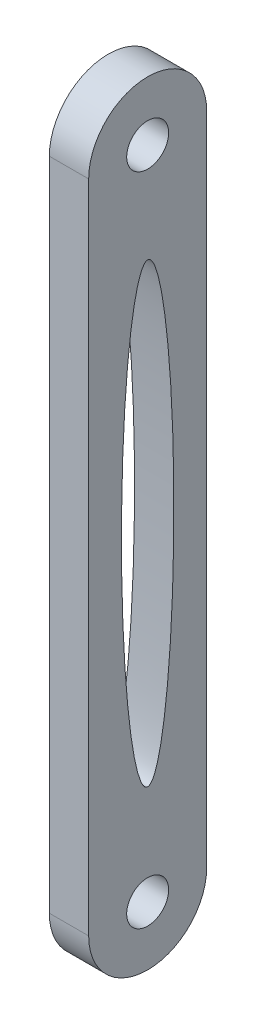
from build123d import *

# Parameters (mm, degrees)
SKETCH1_R           = 1.6
SKETCH1_RX          = 17.4
SKETCH1_RY          = 2
BOSS_EXTRUDE1_DEPTH = 3


with BuildPart() as part:
    # Sketch1 → Boss-Extrude1 (new body)
    with BuildSketch(Plane(origin=(0, 0, 0), x_dir=(0, 0, -1), z_dir=(1, 0, 0))):
        with BuildLine():
            Line((-4.5, 0), (-4.5, 50))
            ThreePointArc((-4.5, 50), (0, 54.5), (4.5, 50))
            Line((4.5, 50), (4.5, 0))
            ThreePointArc((4.5, 0), (0, -4.5), (-4.5, 0))
        make_face()
        with Locations((0, 50)):
            Circle(SKETCH1_R, mode=Mode.SUBTRACT)
        Circle(SKETCH1_R, mode=Mode.SUBTRACT)
        with Locations(Location((0, 25), (0, 0, 90))):
            Ellipse(SKETCH1_RX, SKETCH1_RY, mode=Mode.SUBTRACT)
    extrude(amount=BOSS_EXTRUDE1_DEPTH)


solid = part.part
